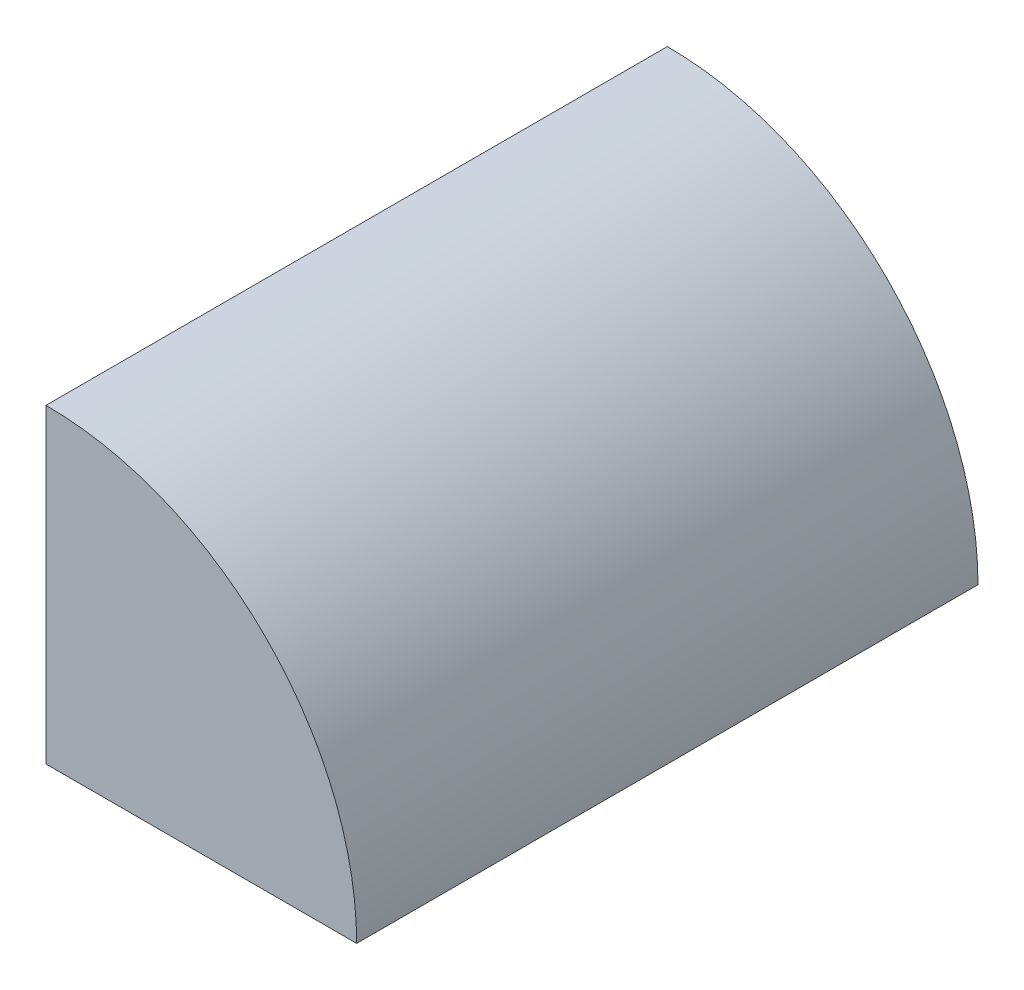
from build123d import *

# Parameters (mm, degrees)
EXTRUDE1_DEPTH = 12.7


with BuildPart() as part:
    # Sketch1 → Extrude1 (new body, symmetric)
    with BuildSketch(Plane.XY):
        with BuildLine():
            Line((12.7, 0), (0, 0))
            Line((0, 0), (0, 12.7))
            ThreePointArc((0, 12.7), (8.980256121, 8.980256121), (12.7, 0))
        make_face()
    extrude(amount=EXTRUDE1_DEPTH, both=True)


solid = part.part
